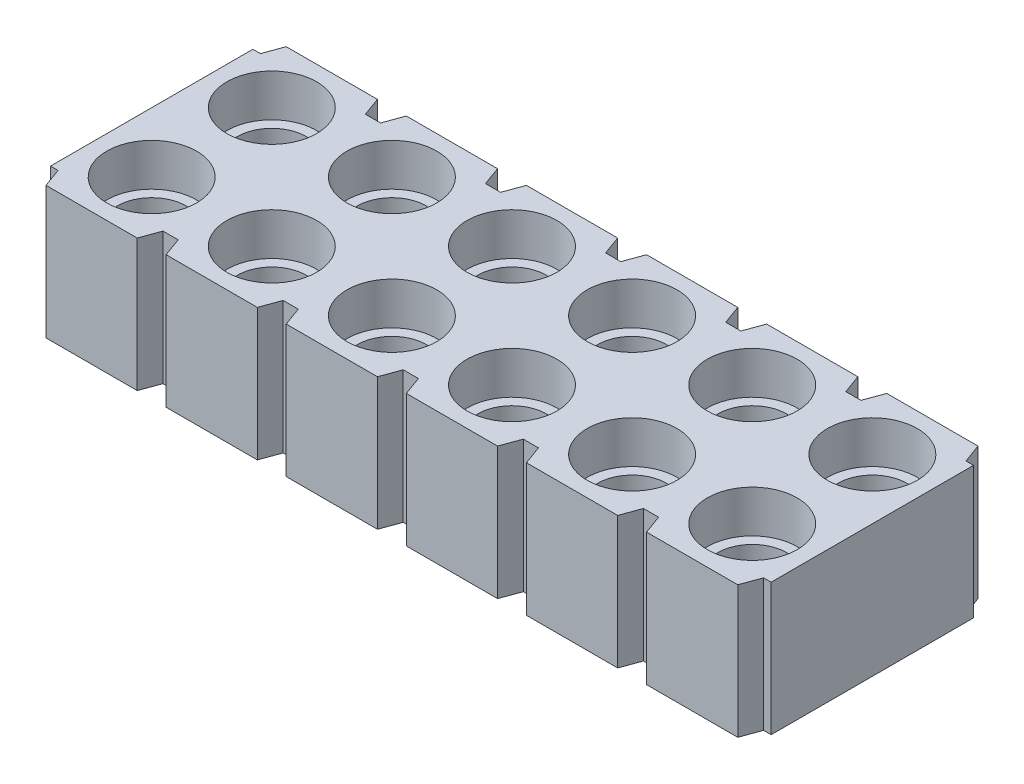
from build123d import *

# Parameters (mm, degrees)
EXTRUDE1_DEPTH          = 2.794
HOLE1_D                 = 1.459992
HOLE1_CBORE_D           = 1.89992
HOLE1_CBORE_DEPTH       = 0.89408
EXTRUDE2_DEPTH          = 2.794
HOLE_PATTERN_COUNT      = 32
HOLE_PATTERN_PITCH      = 2.54
HOLE_PATTERN_COUNT_DIR2 = 2
HOLE_PATTERN_PITCH_DIR2 = 2.54
SLOT_PATTERN_COUNT      = 31
SLOT_PATTERN_PITCH      = 2.54


with BuildPart() as part:
    # Sketch1 → Extrude1 (new body)
    with BuildSketch(Plane(origin=(0, 0, 0), x_dir=(1, 0, 0), z_dir=(0, 1, 0))):
        Polygon((14.934373708, 0.40005), (14.774353708, 0.40005), (14.628747416, 0), (0, 0), (-0.145606292, 0.40005), (-0.305626292, 0.40005), (-0.305626292, 4.67995), (-0.145606292, 4.67995), (0, 5.08), (14.628747416, 5.08), (14.774353708, 4.67995), (14.934373708, 4.67995), align=None)
    extrude(amount=-EXTRUDE1_DEPTH)

    # Hole1 (through all)
    with Locations(Plane(origin=(0.964373708, 0, -1.27), x_dir=(0, 0, 1), z_dir=(0, 1, 0))):
        with Locations((0, 0)):
            hole1 = CounterBoreHole(HOLE1_D / 2, HOLE1_CBORE_D / 2, HOLE1_CBORE_DEPTH)

    # Sketch4 → Extrude2 (cut)
    with BuildSketch(Plane(origin=(0, 0, 0), x_dir=(1, 0, 0), z_dir=(0, 1, 0))):
        Polygon((1.928772816, 0), (2.5399746, 0), (2.394368308, 0.40005), (2.074379108, 0.40005), align=None)
        Polygon((2.074379108, 4.67995), (2.394368308, 4.67995), (2.5399746, 5.08), (1.928772816, 5.08), align=None)
    extrude2 = extrude(amount=-EXTRUDE2_DEPTH, mode=Mode.SUBTRACT)

    # Hole Pattern: Hole1 32 × 2
    with Locations(*[(i * HOLE_PATTERN_PITCH, 0, -j * HOLE_PATTERN_PITCH_DIR2) for i in range(HOLE_PATTERN_COUNT) for j in range(HOLE_PATTERN_COUNT_DIR2) if (i, j) != (0, 0)]):
        add(hole1, mode=Mode.SUBTRACT)

    # Slot Pattern: Extrude2 ×31
    with Locations(*[(i * SLOT_PATTERN_PITCH, 0, 0) for i in range(1, SLOT_PATTERN_COUNT)]):
        add(extrude2, mode=Mode.SUBTRACT)


solid = part.part
